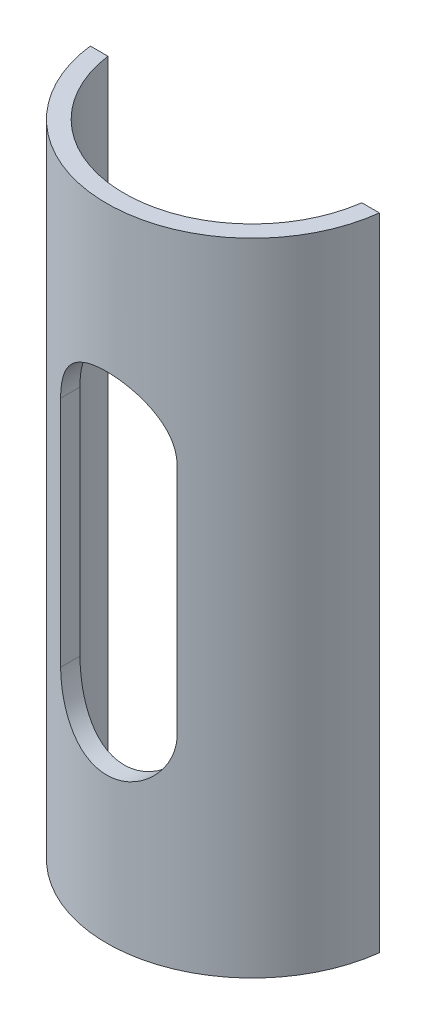
from build123d import *

# Parameters (mm, degrees)
BOSS_EXTRUDE1_DEPTH = 55
CUT_EXTRUDE1_DEPTH  = 80


with BuildPart() as part:
    # Sketch1 → Boss-Extrude1 (new body, symmetric)
    with BuildSketch(Plane(origin=(0, 0, 0), x_dir=(1, 0, 0), z_dir=(0, 1, 0))):
        with BuildLine():
            Line((-24.819347292, -3), (-21.794494718, -3))
            ThreePointArc((-21.794494718, -3), (0, -22), (21.794494718, -3))
            Line((21.794494718, -3), (24.819347292, -3))
            ThreePointArc((24.819347292, -3), (0, -25), (-24.819347292, -3))
        make_face()
    extrude(amount=BOSS_EXTRUDE1_DEPTH, both=True)

    # Sketch2 → Cut-Extrude1 (cut)
    with BuildSketch(Plane.XY):
        with BuildLine():
            Line((-10, -20), (-10, 20))
            ThreePointArc((-10, 20), (0, 30), (10, 20))
            Line((10, 20), (10, -20))
            ThreePointArc((10, -20), (0, -30), (-10, -20))
        make_face()
    extrude(amount=CUT_EXTRUDE1_DEPTH, mode=Mode.SUBTRACT)


solid = part.part
